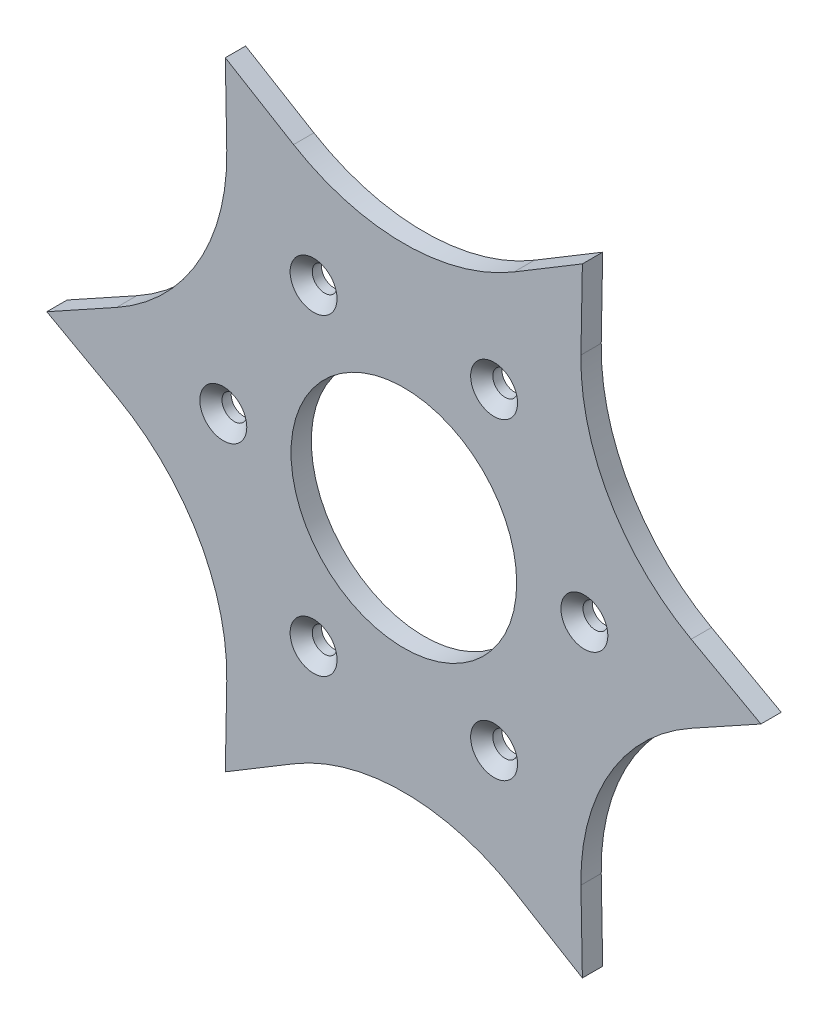
from build123d import *

# Parameters (mm, degrees)
SKETCH7_R           = 25
BOSS_EXTRUDE5_DEPTH = 4.5
CIRPATTERN1_COUNT   = 6


with BuildPart() as part:
    # Sketch7 → Boss-Extrude5 (new body)
    with BuildSketch(Plane.XY.offset(62.545612614)):
        with BuildLine():
            Line((-39.557386288, -68.515402865), (-24.43179769, -59.410864919))
            ThreePointArc((-24.43179769, -59.410864919), (0, -52.625), (24.43179769, -59.410864919))
            Line((24.43179769, -59.410864919), (39.557386288, -68.515402865))
            Line((39.557386288, -68.515402865), (39.235419436, -50.863989919))
            ThreePointArc((39.235419436, -50.863989919), (45.574586874, -26.3125), (63.667217125, -8.546875))
            Line((63.667217125, -8.546875), (79.114772576, 0))
            Line((79.114772576, 0), (63.667217125, 8.546875))
            ThreePointArc((63.667217125, 8.546875), (45.574586874, 26.3125), (39.235419436, 50.863989919))
            Line((39.235419436, 50.863989919), (39.557386288, 68.515402865))
            Line((39.557386288, 68.515402865), (24.43179769, 59.410864919))
            ThreePointArc((24.43179769, 59.410864919), (0, 52.625), (-24.43179769, 59.410864919))
            Line((-24.43179769, 59.410864919), (-39.557386288, 68.515402865))
            Line((-39.557386288, 68.515402865), (-39.235419436, 50.863989919))
            ThreePointArc((-39.235419436, 50.863989919), (-45.574586874, 26.3125), (-63.667217125, 8.546875))
            Line((-63.667217125, 8.546875), (-79.114772576, 0))
            Line((-79.114772576, 0), (-63.667217125, -8.546875))
            ThreePointArc((-63.667217125, -8.546875), (-45.574586874, -26.3125), (-39.235419436, -50.863989919))
            Line((-39.235419436, -50.863989919), (-39.557386288, -68.515402865))
        make_face()
        Circle(SKETCH7_R, mode=Mode.SUBTRACT)
    extrude(amount=BOSS_EXTRUDE5_DEPTH)

    # Sketch11 → CSK for M5 Flat Head Machine Screw1 (revolve, cut)
    with BuildSketch(Plane(origin=(-40, 0, 67.045612614), x_dir=(0, -1, 0), z_dir=(1, 0, 0))):
        Polygon((0, 0), (0, 4.5), (2.75, 4.5), (2.75, 2.45), (5.2, 0), align=None)
    csk_for_m5_flat_head_machine_screw1 = revolve(axis=Axis((-40, 0, 73.395612614), (0, 0, -1)), mode=Mode.SUBTRACT)

    # CirPattern1: CSK for M5 Flat Head Machine Screw1 ×6 about axis
    cirpattern1_axis = Axis((0, 0, 0), (0, 0, 1))
    for i in range(1, CIRPATTERN1_COUNT):
        add(csk_for_m5_flat_head_machine_screw1.rotate(cirpattern1_axis, i * 360 / CIRPATTERN1_COUNT), mode=Mode.SUBTRACT)


solid = part.part
